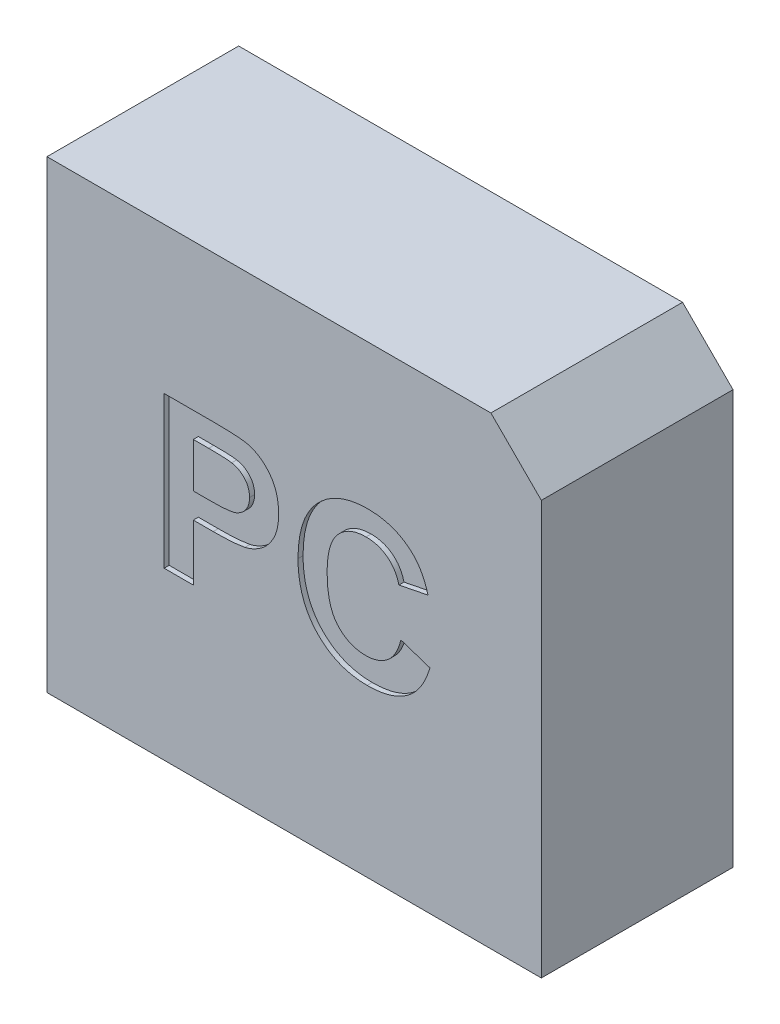
from build123d import *

# Parameters (mm, degrees)
SKETCH1_W           = 490
SKETCH1_H           = 190
BOSS_EXTRUDE1_DEPTH = 460
CUT_EXTRUDE1_DEPTH  = 5
CHAMFER1_SIZE       = 50


with BuildPart() as part:
    # Sketch1 → Boss-Extrude1 (new body)
    with BuildSketch(Plane(origin=(0, 0, 0), x_dir=(1, 0, 0), z_dir=(0, 1, 0))):
        Rectangle(SKETCH1_W, SKETCH1_H)
    extrude(amount=BOSS_EXTRUDE1_DEPTH)

    # Sketch2 → Cut-Extrude1 (cut)
    with BuildSketch(Plane.XY.offset(95)):
        with BuildLine():
            Line((-128.846153846, 164.813155142), (-128.846153846, 314.813155142))
            Line((-128.846153846, 314.813155142), (-80.859375, 314.813155142))
            add(Edge.make_bspline(
                [(-80.859375, 314.813155142), (-78.68582639, 314.810781524), (-74.52865628, 314.806241698), (-68.598704577, 314.680106304), (-63.259671472, 314.501547755), (-58.519480947, 314.279160637), (-54.361453517, 313.947316346), (-50.804241624, 313.563045651), (-47.825445739, 313.149672355), (-46.071321085, 312.721886279), (-45.282451923, 312.529501296)],
                knots=[0, 0, 0, 0, 0.006520502, 0.012471235, 0.0177928, 0.022546478, 0.026706265, 0.030303259, 0.033282265, 0.035716901, 0.035716901, 0.035716901, 0.035716901], degree=3))
            add(Edge.make_bspline(
                [(-45.282451923, 312.529501296), (-44.233447773, 312.230389788), (-42.1514203, 311.636723522), (-39.168524185, 310.371121346), (-36.293484672, 308.904355941), (-33.562423553, 307.156236707), (-30.966057094, 305.157798929), (-28.496667704, 302.925340129), (-26.141086485, 300.448782521), (-23.931899874, 297.733018398), (-21.908544821, 294.791742051), (-20.159857683, 291.620604869), (-18.694823491, 288.233390243), (-17.446638708, 284.655552667), (-16.525722022, 280.848731923), (-15.881247769, 276.839378235), (-15.432613274, 272.625737997), (-15.400848564, 269.742266274), (-15.384615385, 268.268683988)],
                knots=[0, 0, 0, 0, 0.003269584, 0.006489359, 0.009701272, 0.01294382, 0.016201231, 0.01952015, 0.022920764, 0.02644511, 0.030012235, 0.033616627, 0.037289997, 0.041071998, 0.044970961, 0.04902166, 0.053249372, 0.057668074, 0.057668074, 0.057668074, 0.057668074], degree=3))
            add(Edge.make_bspline(
                [(-15.384615385, 268.268683988), (-15.430912329, 266.030881754), (-15.520036489, 261.722989578), (-16.5171777, 255.54710401), (-18.038063347, 249.905830673), (-20.26094761, 244.85350674), (-22.971105302, 240.370306043), (-25.956399797, 236.328721789), (-29.365167403, 232.85057143), (-33.048040103, 229.879723989), (-36.940163439, 227.4485057), (-40.839332316, 225.375926626), (-44.798160315, 223.782461611), (-47.49728043, 223.088176089), (-48.828125, 222.74584745)],
                knots=[0, 0, 0, 0, 0.006707455, 0.012912219, 0.018715467, 0.024191971, 0.029407022, 0.034407026, 0.039230561, 0.043974923, 0.048567956, 0.052976328, 0.057211401, 0.061330619, 0.061330619, 0.061330619, 0.061330619], degree=3))
            add(Edge.make_bspline(
                [(-48.828125, 222.74584745), (-49.778016584, 222.565155747), (-51.780274709, 222.184279197), (-54.955736315, 221.804614598), (-58.426687949, 221.38436728), (-62.207405868, 221.110258367), (-66.29331639, 220.853566863), (-70.68283294, 220.73237433), (-75.36968243, 220.586361937), (-78.595608541, 220.583738277), (-80.258413462, 220.582385911)],
                knots=[0, 0, 0, 0, 0.002899912, 0.006112668, 0.009590206, 0.013388169, 0.017481771, 0.021871362, 0.026560403, 0.031548474, 0.031548474, 0.031548474, 0.031548474], degree=3))
            Line((-80.258413462, 220.582385911), (-100, 220.582385911))
            Line((-100, 220.582385911), (-100, 164.813155142))
            Line((-100, 164.813155142), (-128.846153846, 164.813155142))
        make_face()
        with BuildLine():
            Line((-100, 289.813155142), (-100, 245.582385911))
            Line((-100, 245.582385911), (-82.692307692, 245.582385911))
            add(Edge.make_bspline(
                [(-82.692307692, 245.582385911), (-81.199788789, 245.584318597), (-78.344412345, 245.588016069), (-74.247580544, 245.720733608), (-70.539124515, 245.882739977), (-67.211295568, 246.150893666), (-64.28418136, 246.504313816), (-61.738179725, 246.927048829), (-59.570323356, 247.380687664), (-57.226081821, 248.132439909), (-54.719618929, 249.34870649), (-52.043011123, 251.096787063), (-49.691614325, 253.186823554), (-47.734940523, 255.641499036), (-46.171991363, 258.368785716), (-45.052918625, 261.340733459), (-44.330334411, 264.508086695), (-44.26433293, 266.702194384), (-44.230769231, 267.817962834)],
                knots=[0, 0, 0, 0, 0.004477264, 0.00856557, 0.012295891, 0.015612224, 0.018578929, 0.021137784, 0.02335402, 0.025216517, 0.02850949, 0.031676392, 0.034783136, 0.037903799, 0.041053119, 0.044172624, 0.047402478, 0.05074444, 0.05074444, 0.05074444, 0.05074444], degree=3))
            add(Edge.make_bspline(
                [(-44.230769231, 267.817962834), (-44.278006455, 269.176951385), (-44.369593205, 271.811850999), (-45.379539397, 275.564387794), (-46.937770963, 278.969860429), (-49.16559971, 281.922309278), (-51.856764402, 284.405075963), (-54.881521201, 286.470826116), (-58.304465157, 287.916453798), (-60.726992003, 288.476581161), (-61.959134615, 288.76147245)],
                knots=[0, 0, 0, 0, 0.004067604, 0.007886548, 0.011569736, 0.015241631, 0.018898372, 0.022515267, 0.026176696, 0.029966568, 0.029966568, 0.029966568, 0.029966568], degree=3))
            add(Edge.make_bspline(
                [(-61.959134615, 288.76147245), (-62.489353732, 288.846276674), (-63.666275778, 289.03451576), (-65.622559738, 289.230966655), (-67.936843968, 289.409638547), (-70.611918115, 289.556333509), (-73.637178853, 289.671015001), (-77.022604854, 289.771504272), (-80.759279952, 289.779577251), (-83.373421904, 289.801652406), (-84.735576923, 289.813155142)],
                knots=[0, 0, 0, 0, 0.001610588, 0.003575006, 0.005895722, 0.008574218, 0.011611452, 0.014978044, 0.018734174, 0.022820823, 0.022820823, 0.022820823, 0.022820823], degree=3))
            Line((-84.735576923, 289.813155142), (-100, 289.813155142))
        make_face(mode=Mode.SUBTRACT)
        with BuildLine():
            Line((105.769230769, 220.582385911), (134.615384615, 210.967001296))
            add(Edge.make_bspline(
                [(134.615384615, 210.967001296), (134.029141984, 209.075631653), (132.881094494, 205.371734914), (130.773086835, 200.063171409), (128.362612777, 195.143483588), (125.736358285, 190.555089772), (122.731001789, 186.416523041), (119.514799096, 182.590757925), (115.992119669, 179.158372336), (112.18034538, 176.11203688), (108.116166692, 173.418096149), (103.752373829, 171.140664307), (99.15409023, 169.179171274), (94.2746867, 167.58994837), (89.146546246, 166.31722205), (83.745607291, 165.476579401), (78.097134874, 164.906595914), (74.24027675, 164.84479583), (72.265625, 164.813155142)],
                knots=[0, 0, 0, 0, 0.005938963, 0.011630357, 0.017113287, 0.022364828, 0.027468138, 0.032435168, 0.037343685, 0.042195961, 0.047054652, 0.051947232, 0.056942267, 0.062035394, 0.067326331, 0.072775067, 0.078420028, 0.084342245, 0.084342245, 0.084342245, 0.084342245], degree=3))
            add(Edge.make_bspline(
                [(72.265625, 164.813155142), (69.828320913, 164.863553304), (65.034070892, 164.962687995), (58.022934328, 165.96061555), (51.341638203, 167.517620504), (44.980624497, 169.673266776), (38.982352083, 172.52841479), (33.29209629, 175.965642858), (27.95126874, 180.054732283), (22.978605948, 184.72676615), (18.460821572, 189.946078551), (14.554106834, 195.684465819), (11.215954183, 201.861087994), (8.517887096, 208.505395954), (6.408180701, 215.610567139), (4.930326995, 223.166777517), (4.005580121, 231.1764073), (3.900224439, 236.665511085), (3.846153846, 239.482626296)],
                knots=[0, 0, 0, 0, 0.007307863, 0.014374785, 0.021196757, 0.02786743, 0.034480533, 0.041087011, 0.047775932, 0.054620829, 0.061523782, 0.068441368, 0.075405525, 0.082547871, 0.08991578, 0.097606033, 0.105619636, 0.114068491, 0.114068491, 0.114068491, 0.114068491], degree=3))
            add(Edge.make_bspline(
                [(3.846153846, 239.482626296), (3.899980719, 242.44994243), (4.004987128, 248.238634787), (4.931466399, 256.654897887), (6.369770291, 264.586735222), (8.483042384, 271.984966239), (11.141460959, 278.901657134), (14.483666479, 285.268146449), (18.351411861, 291.169316884), (22.848692346, 296.497007238), (27.844017445, 301.227275851), (33.197126129, 305.41011212), (38.957958096, 308.919211853), (45.094988778, 311.788769997), (51.61644901, 314.009375314), (58.509506337, 315.608385438), (65.7798005, 316.539112152), (70.750536696, 316.669626494), (73.287259615, 316.736232065)],
                knots=[0, 0, 0, 0, 0.008899305, 0.01736092, 0.025370015, 0.033055277, 0.040409694, 0.047559684, 0.054585153, 0.061537242, 0.068423432, 0.075191124, 0.081880179, 0.088614838, 0.095475545, 0.10250917, 0.10981042, 0.117419765, 0.117419765, 0.117419765, 0.117419765], degree=3))
            add(Edge.make_bspline(
                [(73.287259615, 316.736232065), (75.502677767, 316.680409273), (79.846299878, 316.57096126), (86.207093386, 315.827367435), (92.235345549, 314.522409911), (97.96364103, 312.761007439), (103.359371222, 310.436424746), (108.432202552, 307.59580863), (113.19957157, 304.254188874), (116.072009551, 301.643988063), (117.518028846, 300.329982065)],
                knots=[0, 0, 0, 0, 0.006646129, 0.013030621, 0.019177564, 0.025126932, 0.030982068, 0.036766615, 0.042544135, 0.048401044, 0.048401044, 0.048401044, 0.048401044], degree=3))
            add(Edge.make_bspline(
                [(117.518028846, 300.329982065), (118.356122646, 299.493866704), (120.05199646, 297.801996242), (122.316463998, 294.945639513), (124.463460545, 291.870771008), (126.458908982, 288.524937396), (128.239741929, 284.882854201), (129.8916547, 281.000452219), (131.412508813, 276.86276611), (132.25827859, 273.983192235), (132.692307692, 272.505462834)],
                knots=[0, 0, 0, 0, 0.003548855, 0.007181069, 0.010915382, 0.014795774, 0.018854045, 0.023067852, 0.027450032, 0.03206943, 0.03206943, 0.03206943, 0.03206943], degree=3))
            Line((132.692307692, 272.505462834), (103.846153846, 266.736232065))
            add(Edge.make_bspline(
                [(103.846153846, 266.736232065), (103.600973397, 267.682387584), (103.118032237, 269.54606572), (102.140866518, 272.224068854), (101.019980393, 274.765254654), (99.630744694, 277.107380608), (98.155017147, 279.354641299), (96.407838995, 281.407251388), (94.5007912, 283.319005273), (92.420135671, 285.070063602), (90.190676804, 286.62504353), (87.855339597, 288.022873638), (85.371678335, 289.163939789), (82.772731821, 290.087059632), (80.068851446, 290.861026069), (77.235964389, 291.339141204), (74.29840182, 291.706179115), (72.29693637, 291.726067579), (71.274038462, 291.736232065)],
                knots=[0, 0, 0, 0, 0.002930573, 0.005772461, 0.008542757, 0.011248585, 0.013932133, 0.016598296, 0.019317938, 0.022026435, 0.024744084, 0.027465053, 0.030180708, 0.032927601, 0.035734323, 0.038604662, 0.041538007, 0.044604236, 0.044604236, 0.044604236, 0.044604236], degree=3))
            add(Edge.make_bspline(
                [(71.274038462, 291.736232065), (69.86927788, 291.707862303), (67.127605565, 291.652493018), (63.120231411, 291.03516297), (59.300748387, 290.17361501), (55.684560232, 288.858035731), (52.294061085, 287.175420708), (49.090717698, 285.130014002), (46.092111739, 282.730576574), (43.297229728, 279.948683004), (40.789203011, 276.734035281), (38.584289533, 273.079996309), (36.755116153, 268.945080948), (35.27011826, 264.369865693), (34.101255741, 259.34347067), (33.266595883, 253.85944922), (32.80500389, 247.914049762), (32.7306837, 243.800308997), (32.692307692, 241.676135911)],
                knots=[0, 0, 0, 0, 0.004210592, 0.008217816, 0.012138946, 0.015940948, 0.019730463, 0.023473107, 0.027321138, 0.031230623, 0.035275969, 0.039522221, 0.044000997, 0.048809065, 0.053932857, 0.059465947, 0.06543486, 0.071807603, 0.071807603, 0.071807603, 0.071807603], degree=3))
            add(Edge.make_bspline(
                [(32.692307692, 241.676135911), (32.730305822, 239.421801013), (32.803522365, 235.078044909), (33.265016423, 228.812578486), (34.105013548, 223.050006886), (35.25834191, 217.780103579), (36.750823247, 213.00609642), (38.576903306, 208.736246769), (40.747764015, 204.965554134), (43.260027956, 201.696529353), (46.050180804, 198.888447148), (49.04265338, 196.474135787), (52.219790696, 194.409909096), (55.600711353, 192.711596469), (59.198274551, 191.426841862), (62.982913624, 190.495115298), (66.968515038, 189.902801915), (69.699399362, 189.843456212), (71.09375, 189.813155142)],
                knots=[0, 0, 0, 0, 0.006763221, 0.013031685, 0.018832209, 0.02421962, 0.029199268, 0.033815536, 0.038124058, 0.042216888, 0.046147677, 0.049972291, 0.053731184, 0.057493799, 0.061295801, 0.065165592, 0.069172816, 0.073353388, 0.073353388, 0.073353388, 0.073353388], degree=3))
            add(Edge.make_bspline(
                [(71.09375, 189.813155142), (72.126076347, 189.838910052), (74.155992848, 189.88955326), (77.156365937, 190.210981824), (80.036112192, 190.824381907), (82.809327067, 191.635492498), (85.48678539, 192.653197007), (88.02764717, 193.958707247), (90.48190273, 195.459197387), (92.798628231, 197.217656853), (95.0088458, 199.191863347), (97.024695379, 201.473554028), (98.894563209, 204.007905032), (100.59472722, 206.811853475), (102.181995284, 209.861398577), (103.532451036, 213.204053883), (104.790521611, 216.785800522), (105.437296252, 219.294753392), (105.769230769, 220.582385911)],
                knots=[0, 0, 0, 0, 0.003097285, 0.006090351, 0.009036902, 0.011917915, 0.014752645, 0.017614951, 0.020475206, 0.023371847, 0.02632895, 0.029350837, 0.032487948, 0.035765531, 0.039178998, 0.042789396, 0.046571398, 0.050558745, 0.050558745, 0.050558745, 0.050558745], degree=3))
        make_face()
    extrude(amount=-CUT_EXTRUDE1_DEPTH, mode=Mode.SUBTRACT)

    # Chamfer1
    chamfer1_edges = [part.edges().sort_by_distance(p)[0] for p in [
        (245, 460, 0),
    ]]
    chamfer(chamfer1_edges, length=CHAMFER1_SIZE)


solid = part.part
